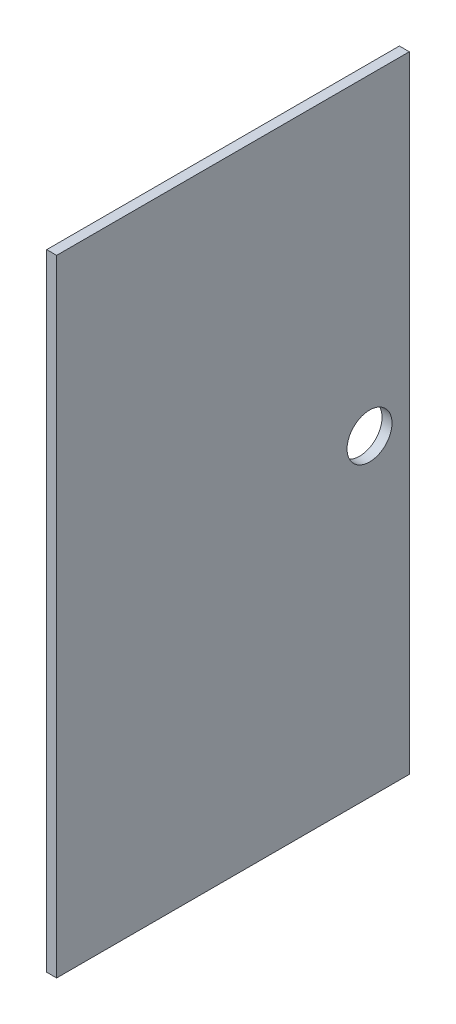
from build123d import *

# Parameters (mm, degrees)
SKETCH1_W               = 225.298
SKETCH1_H               = 399.796
BOSS_EXTRUDE1_DEPTH     = 6.35
SKETCH2_R               = 14.351
CUT_EXTRUDE1_DEPTH      = 1
CUT_EXTRUDE1_DEPTH_BACK = 7.35


with BuildPart() as part:
    # Sketch1 → Boss-Extrude1 (new body)
    with BuildSketch(Plane(origin=(0, 0, 0), x_dir=(0, 0, -1), z_dir=(1, 0, 0))):
        with Locations((112.649, 199.898)):
            Rectangle(SKETCH1_W, SKETCH1_H)
    extrude(amount=BOSS_EXTRUDE1_DEPTH)

    # Sketch2 → Cut-Extrude1 (cut, two sides)
    with BuildSketch(Plane(origin=(6.35, 0, 0), x_dir=(0, 0, -1), z_dir=(1, 0, 0))) as cut_extrude1_sk:
        with Locations((199.898, 199.898)):
            Circle(SKETCH2_R)
    extrude(amount=CUT_EXTRUDE1_DEPTH, mode=Mode.SUBTRACT)
    extrude(cut_extrude1_sk.sketch, amount=-CUT_EXTRUDE1_DEPTH_BACK, mode=Mode.SUBTRACT)


solid = part.part
